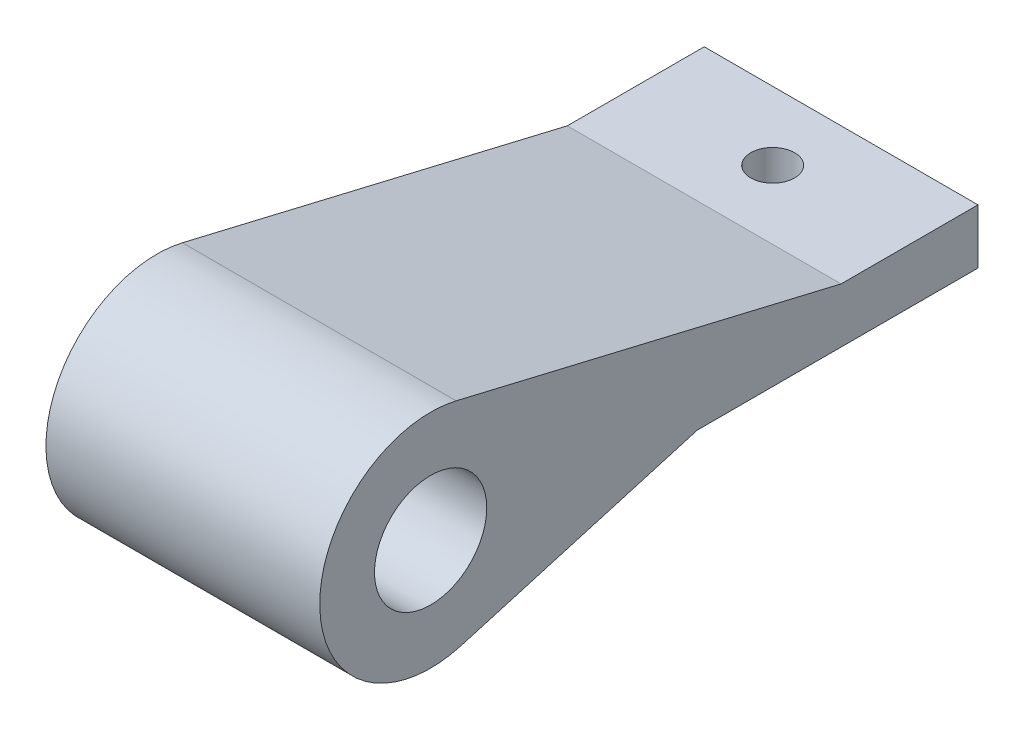
from build123d import *

# Parameters (mm, degrees)
SKETCH1_R           = 4.1
BOSS_EXTRUDE1_DEPTH = 20
SKETCH2_R           = 1.6
CUT_EXTRUDE1_DEPTH  = 10.320966192


with BuildPart() as part:
    # Sketch1 → Boss-Extrude1 (new body)
    with BuildSketch(Plane(origin=(0, 0, 0), x_dir=(0, 0, -1), z_dir=(1, 0, 0))):
        with BuildLine():
            Line((-10.25, 0), (10.25, 0))
            Line((10.25, 0), (10.25, 4))
            Line((10.25, 4), (0.25, 4))
            Line((0.25, 4), (-27.869263808, 10.660915614))
            ThreePointArc((-27.869263808, 10.660915614), (-37.833813874, 2.577122842), (-27.47875844, -5))
            Line((-27.47875844, -5), (-10.25, 0))
        make_face()
        with Locations((-29.736330811, 2.779033808)):
            Circle(SKETCH1_R, mode=Mode.SUBTRACT)
    extrude(amount=BOSS_EXTRUDE1_DEPTH)

    # Sketch2 → Cut-Extrude1 (cut, through all)
    with BuildSketch(Plane(origin=(0, 4, 0), x_dir=(1, 0, 0), z_dir=(0, 1, 0))):
        with Locations((10, 5.25)):
            Circle(SKETCH2_R)
    extrude(amount=-CUT_EXTRUDE1_DEPTH, mode=Mode.SUBTRACT)


solid = part.part
